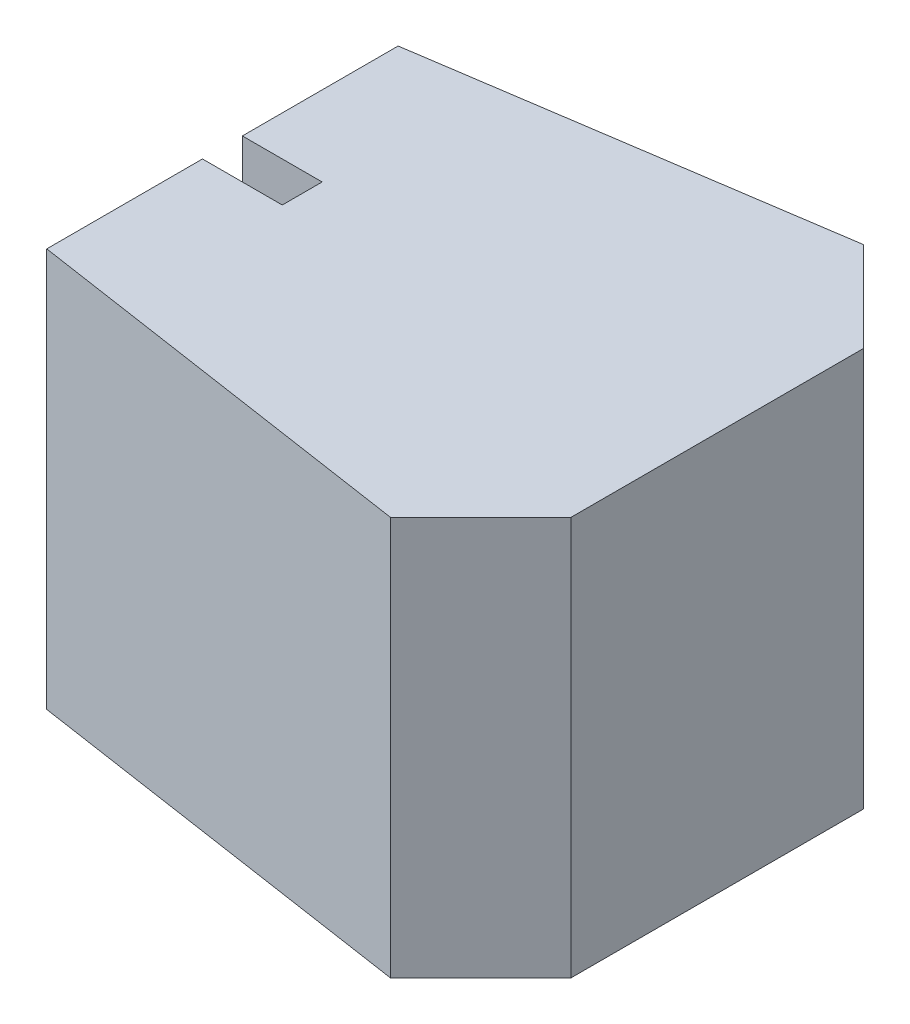
from build123d import *

# Parameters (mm, degrees)
BOSS_EXTRUDE1_DEPTH = 500


with BuildPart() as part:
    # Sketch1 → Boss-Extrude1 (new body)
    with BuildSketch(Plane(origin=(0, 0, 0), x_dir=(1, 0, 0), z_dir=(0, 1, 0))):
        Polygon((100, 25), (100, -25), (0, -25), (0, -200), (0, -220.223748416), (507.009150288, -296.275120959), (620, -183.284271247), (620, 183.284271247), (507.009150288, 296.275120959), (0, 220.223748416), (0, 200), (0, 25), align=None)
    extrude(amount=BOSS_EXTRUDE1_DEPTH)


solid = part.part
